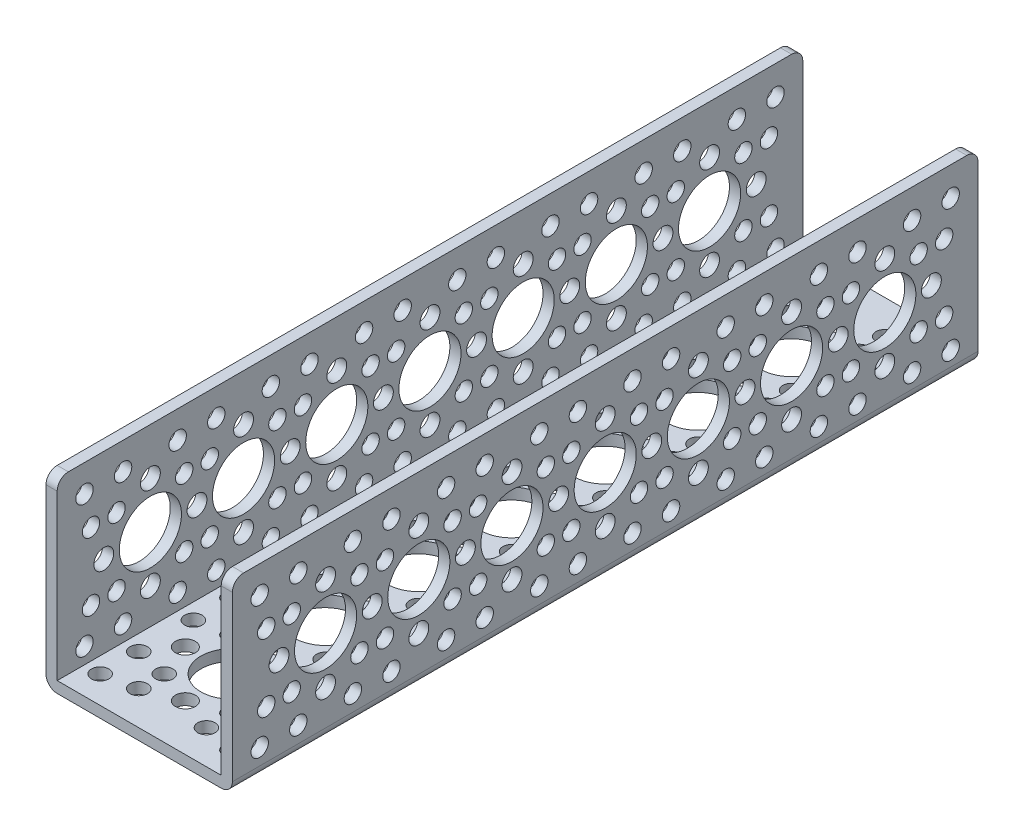
from build123d import *

# Parameters (mm, degrees)
EXTRUDE_THIN1_DEPTH = 152.4
SKETCH3_R           = 6.35
SKETCH3_R_2         = 2.032
SKETCH3_R_3         = 1.778
CUT_EXTRUDE1_DEPTH  = 2.286
SKETCH4_R           = 6.35
SKETCH4_R_2         = 2.032
SKETCH4_R_3         = 1.778
CUT_EXTRUDE2_DEPTH  = 39.1
FILLET1_R           = 2.286


with BuildPart() as part:
    # Sketch1 → Extrude-Thin1 (new body)
    with BuildSketch(Plane.XY):
        Polygon((0, 38.1), (0, 0), (38.1, 0), (38.1, 38.1), (35.814, 38.1), (35.814, 2.286), (2.286, 2.286), (2.286, 38.1), align=None)
    extrude(amount=EXTRUDE_THIN1_DEPTH)

    # Sketch3 → Cut-Extrude1 (cut)
    with BuildSketch(Plane.XZ):
        with Locations((19.05, 19.058384182)):
            Circle(SKETCH3_R)
        with Locations((19.05, 9.533384182)):
            Circle(SKETCH3_R_2)
        with Locations((9.525, 19.058384182)):
            Circle(SKETCH3_R_2)
        with Locations((19.05, 28.583384182)):
            Circle(SKETCH3_R_2)
        with Locations((28.575, 19.058384182)):
            Circle(SKETCH3_R_2)
        with Locations((12.135202787, 25.973181395)):
            Circle(SKETCH3_R_3)
        with Locations((5.579615818, 32.528768363)):
            Circle(SKETCH3_R_3)
        with Locations((25.964797213, 25.973181395)):
            Circle(SKETCH3_R_3)
        with Locations((32.520384182, 32.528768363)):
            Circle(SKETCH3_R_3)
        with Locations((25.964797213, 12.143586968)):
            Circle(SKETCH3_R_3)
        with Locations((32.520384182, 5.588)):
            Circle(SKETCH3_R_3)
        with Locations((12.135202787, 12.143586968)):
            Circle(SKETCH3_R_3)
        with Locations((5.579615818, 5.588)):
            Circle(SKETCH3_R_3)
        with Locations((12.135202787, 31.193586968)):
            Circle(SKETCH3_R_3)
        with Locations((25.964797213, 31.193586968)):
            Circle(SKETCH3_R_3)
        with Locations((25.964797213, 6.923181395)):
            Circle(SKETCH3_R_3)
        with Locations((12.135202787, 6.923181395)):
            Circle(SKETCH3_R_3)
        with Locations((32.520384182, 13.478768363)):
            Circle(SKETCH3_R_3)
        with Locations((5.579615818, 13.478768363)):
            Circle(SKETCH3_R_3)
        with Locations((5.579615818, 24.638)):
            Circle(SKETCH3_R_3)
        with Locations((32.520384182, 24.638)):
            Circle(SKETCH3_R_3)
        with Locations((18.971313238, 38.108384182)):
            Circle(SKETCH3_R)
        with Locations((9.446313238, 38.108384182)):
            Circle(SKETCH3_R_2)
        with Locations((28.496313238, 38.108384182)):
            Circle(SKETCH3_R_2)
        with Locations((18.971313238, 57.158384182)):
            Circle(SKETCH3_R)
        with Locations((18.971313238, 47.633384182)):
            Circle(SKETCH3_R_2)
        with Locations((9.446313238, 57.158384182)):
            Circle(SKETCH3_R_2)
        with Locations((18.971313238, 66.683384182)):
            Circle(SKETCH3_R_2)
        with Locations((28.496313238, 57.158384182)):
            Circle(SKETCH3_R_2)
        with Locations((12.056516025, 64.073181395)):
            Circle(SKETCH3_R_3)
        with Locations((5.500929056, 70.628768363)):
            Circle(SKETCH3_R_3)
        with Locations((25.886110451, 64.073181395)):
            Circle(SKETCH3_R_3)
        with Locations((32.441697419, 70.628768363)):
            Circle(SKETCH3_R_3)
        with Locations((25.886110451, 50.243586968)):
            Circle(SKETCH3_R_3)
        with Locations((32.441697419, 43.688)):
            Circle(SKETCH3_R_3)
        with Locations((12.056516025, 50.243586968)):
            Circle(SKETCH3_R_3)
        with Locations((5.500929056, 43.688)):
            Circle(SKETCH3_R_3)
        with Locations((12.056516025, 69.293586968)):
            Circle(SKETCH3_R_3)
        with Locations((25.886110451, 69.293586968)):
            Circle(SKETCH3_R_3)
        with Locations((25.886110451, 45.023181395)):
            Circle(SKETCH3_R_3)
        with Locations((12.056516025, 45.023181395)):
            Circle(SKETCH3_R_3)
        with Locations((32.441697419, 51.578768363)):
            Circle(SKETCH3_R_3)
        with Locations((5.500929056, 51.578768363)):
            Circle(SKETCH3_R_3)
        with Locations((5.500929056, 62.738)):
            Circle(SKETCH3_R_3)
        with Locations((32.441697419, 62.738)):
            Circle(SKETCH3_R_3)
        with Locations((18.971313238, 76.208384182)):
            Circle(SKETCH3_R)
        with Locations((9.446313238, 76.208384182)):
            Circle(SKETCH3_R_2)
        with Locations((28.496313238, 76.208384182)):
            Circle(SKETCH3_R_2)
        with Locations((18.971313238, 95.258384182)):
            Circle(SKETCH3_R)
        with Locations((18.971313238, 85.733384182)):
            Circle(SKETCH3_R_2)
        with Locations((9.446313238, 95.258384182)):
            Circle(SKETCH3_R_2)
        with Locations((18.971313238, 104.783384182)):
            Circle(SKETCH3_R_2)
        with Locations((28.496313238, 95.258384182)):
            Circle(SKETCH3_R_2)
        with Locations((12.056516025, 102.173181395)):
            Circle(SKETCH3_R_3)
        with Locations((5.500929056, 108.728768363)):
            Circle(SKETCH3_R_3)
        with Locations((25.886110451, 102.173181395)):
            Circle(SKETCH3_R_3)
        with Locations((32.441697419, 108.728768363)):
            Circle(SKETCH3_R_3)
        with Locations((25.886110451, 88.343586968)):
            Circle(SKETCH3_R_3)
        with Locations((32.441697419, 81.788)):
            Circle(SKETCH3_R_3)
        with Locations((12.056516025, 88.343586968)):
            Circle(SKETCH3_R_3)
        with Locations((5.500929056, 81.788)):
            Circle(SKETCH3_R_3)
        with Locations((12.056516025, 107.393586968)):
            Circle(SKETCH3_R_3)
        with Locations((25.886110451, 107.393586968)):
            Circle(SKETCH3_R_3)
        with Locations((25.886110451, 83.123181395)):
            Circle(SKETCH3_R_3)
        with Locations((12.056516025, 83.123181395)):
            Circle(SKETCH3_R_3)
        with Locations((32.441697419, 89.678768363)):
            Circle(SKETCH3_R_3)
        with Locations((5.500929056, 89.678768363)):
            Circle(SKETCH3_R_3)
        with Locations((5.500929056, 100.838)):
            Circle(SKETCH3_R_3)
        with Locations((32.441697419, 100.838)):
            Circle(SKETCH3_R_3)
        with Locations((18.971313238, 133.358384182)):
            Circle(SKETCH3_R)
        with Locations((18.971313238, 123.833384182)):
            Circle(SKETCH3_R_2)
        with Locations((9.446313238, 133.358384182)):
            Circle(SKETCH3_R_2)
        with Locations((18.971313238, 142.883384182)):
            Circle(SKETCH3_R_2)
        with Locations((28.496313238, 133.358384182)):
            Circle(SKETCH3_R_2)
        with Locations((12.056516025, 140.273181395)):
            Circle(SKETCH3_R_3)
        with Locations((5.500929056, 146.828768363)):
            Circle(SKETCH3_R_3)
        with Locations((25.886110451, 140.273181395)):
            Circle(SKETCH3_R_3)
        with Locations((32.441697419, 146.828768363)):
            Circle(SKETCH3_R_3)
        with Locations((25.886110451, 126.443586968)):
            Circle(SKETCH3_R_3)
        with Locations((32.441697419, 119.888)):
            Circle(SKETCH3_R_3)
        with Locations((12.056516025, 126.443586968)):
            Circle(SKETCH3_R_3)
        with Locations((5.500929056, 119.888)):
            Circle(SKETCH3_R_3)
        with Locations((12.056516025, 145.493586968)):
            Circle(SKETCH3_R_3)
        with Locations((25.886110451, 145.493586968)):
            Circle(SKETCH3_R_3)
        with Locations((25.886110451, 121.223181395)):
            Circle(SKETCH3_R_3)
        with Locations((12.056516025, 121.223181395)):
            Circle(SKETCH3_R_3)
        with Locations((32.441697419, 127.778768363)):
            Circle(SKETCH3_R_3)
        with Locations((5.500929056, 127.778768363)):
            Circle(SKETCH3_R_3)
        with Locations((5.500929056, 138.938)):
            Circle(SKETCH3_R_3)
        with Locations((32.441697419, 138.938)):
            Circle(SKETCH3_R_3)
        with Locations((18.971313238, 114.308384182)):
            Circle(SKETCH3_R)
        with Locations((9.446313238, 114.308384182)):
            Circle(SKETCH3_R_2)
        with Locations((28.496313238, 114.308384182)):
            Circle(SKETCH3_R_2)
    extrude(amount=-CUT_EXTRUDE1_DEPTH, mode=Mode.SUBTRACT)

    # Sketch4 → Cut-Extrude2 (cut, through all)
    with BuildSketch(Plane.ZY):
        with Locations((114.3, 19.05)):
            Circle(SKETCH4_R)
        with Locations((114.3, 9.525)):
            Circle(SKETCH4_R_2)
        with Locations((114.3, 28.575)):
            Circle(SKETCH4_R_2)
        with Locations((95.25, 19.05)):
            Circle(SKETCH4_R)
        with Locations((104.774999983, 19.049430852)):
            Circle(SKETCH4_R_2)
        with Locations((95.249430852, 9.525000017)):
            Circle(SKETCH4_R_2)
        with Locations((85.725000017, 19.050569148)):
            Circle(SKETCH4_R_2)
        with Locations((95.250569148, 28.574999983)):
            Circle(SKETCH4_R_2)
        with Locations((88.334789619, 12.13561598)):
            Circle(SKETCH4_R_3)
        with Locations((81.778810945, 5.58042074)):
            Circle(SKETCH4_R_3)
        with Locations((88.33561598, 25.965210381)):
            Circle(SKETCH4_R_3)
        with Locations((81.78042074, 32.521189055)):
            Circle(SKETCH4_R_3)
        with Locations((102.165210381, 25.96438402)):
            Circle(SKETCH4_R_3)
        with Locations((108.721189055, 32.51957926)):
            Circle(SKETCH4_R_3)
        with Locations((102.16438402, 12.134789619)):
            Circle(SKETCH4_R_3)
        with Locations((108.71957926, 5.578810945)):
            Circle(SKETCH4_R_3)
        with Locations((83.114384054, 12.135927915)):
            Circle(SKETCH4_R_3)
        with Locations((83.115210415, 25.965522317)):
            Circle(SKETCH4_R_3)
        with Locations((107.385615946, 25.964072085)):
            Circle(SKETCH4_R_3)
        with Locations((107.384789585, 12.134477683)):
            Circle(SKETCH4_R_3)
        with Locations((100.830420706, 32.520050758)):
            Circle(SKETCH4_R_3)
        with Locations((100.828810911, 5.579282443)):
            Circle(SKETCH4_R_3)
        with Locations((89.669579294, 5.579949242)):
            Circle(SKETCH4_R_3)
        with Locations((89.671189089, 32.520717557)):
            Circle(SKETCH4_R_3)
        with Locations((133.35, 19.05)):
            Circle(SKETCH4_R)
        with Locations((142.875, 19.05)):
            Circle(SKETCH4_R_2)
        with Locations((133.35, 9.525)):
            Circle(SKETCH4_R_2)
        with Locations((123.825, 19.05)):
            Circle(SKETCH4_R_2)
        with Locations((133.35, 28.575)):
            Circle(SKETCH4_R_2)
        with Locations((126.435202787, 12.135202787)):
            Circle(SKETCH4_R_3)
        with Locations((119.879615818, 5.579615818)):
            Circle(SKETCH4_R_3)
        with Locations((126.435202787, 25.964797213)):
            Circle(SKETCH4_R_3)
        with Locations((119.879615818, 32.520384182)):
            Circle(SKETCH4_R_3)
        with Locations((140.264797213, 25.964797213)):
            Circle(SKETCH4_R_3)
        with Locations((146.820384182, 32.520384182)):
            Circle(SKETCH4_R_3)
        with Locations((140.264797213, 12.135202787)):
            Circle(SKETCH4_R_3)
        with Locations((146.820384182, 5.579615818)):
            Circle(SKETCH4_R_3)
        with Locations((121.214797213, 12.135202787)):
            Circle(SKETCH4_R_3)
        with Locations((121.214797213, 25.964797213)):
            Circle(SKETCH4_R_3)
        with Locations((145.485202787, 25.964797213)):
            Circle(SKETCH4_R_3)
        with Locations((145.485202787, 12.135202787)):
            Circle(SKETCH4_R_3)
        with Locations((138.929615818, 32.520384182)):
            Circle(SKETCH4_R_3)
        with Locations((138.929615818, 5.579615818)):
            Circle(SKETCH4_R_3)
        with Locations((127.770384182, 5.579615818)):
            Circle(SKETCH4_R_3)
        with Locations((127.770384182, 32.520384182)):
            Circle(SKETCH4_R_3)
        with Locations((76.200189489, 18.96503245)):
            Circle(SKETCH4_R)
        with Locations((76.200189489, 9.44003245)):
            Circle(SKETCH4_R_2)
        with Locations((76.200189489, 28.49003245)):
            Circle(SKETCH4_R_2)
        with Locations((57.150378977, 18.880064901)):
            Circle(SKETCH4_R)
        with Locations((66.67537896, 18.879495752)):
            Circle(SKETCH4_R_2)
        with Locations((57.149809829, 9.355064918)):
            Circle(SKETCH4_R_2)
        with Locations((47.625378994, 18.880634049)):
            Circle(SKETCH4_R_2)
        with Locations((57.150948126, 28.405064884)):
            Circle(SKETCH4_R_2)
        with Locations((50.235168596, 11.96568088)):
            Circle(SKETCH4_R_3)
        with Locations((43.679189923, 5.41048564)):
            Circle(SKETCH4_R_3)
        with Locations((50.235994957, 25.795275282)):
            Circle(SKETCH4_R_3)
        with Locations((43.680799717, 32.351253955)):
            Circle(SKETCH4_R_3)
        with Locations((64.065589359, 25.794448921)):
            Circle(SKETCH4_R_3)
        with Locations((70.621568032, 32.349644161)):
            Circle(SKETCH4_R_3)
        with Locations((64.064762998, 11.964854519)):
            Circle(SKETCH4_R_3)
        with Locations((70.619958238, 5.408875846)):
            Circle(SKETCH4_R_3)
        with Locations((45.014763032, 11.965992816)):
            Circle(SKETCH4_R_3)
        with Locations((45.015589393, 25.795587217)):
            Circle(SKETCH4_R_3)
        with Locations((69.285994923, 25.794136985)):
            Circle(SKETCH4_R_3)
        with Locations((69.285168562, 11.964542584)):
            Circle(SKETCH4_R_3)
        with Locations((62.730799683, 32.350115659)):
            Circle(SKETCH4_R_3)
        with Locations((62.729189889, 5.409347344)):
            Circle(SKETCH4_R_3)
        with Locations((51.569958272, 5.410014142)):
            Circle(SKETCH4_R_3)
        with Locations((51.571568066, 32.350782457)):
            Circle(SKETCH4_R_3)
        with Locations((38.100568466, 18.795097351)):
            Circle(SKETCH4_R)
        with Locations((38.100568466, 9.270097351)):
            Circle(SKETCH4_R_2)
        with Locations((38.100568466, 28.320097351)):
            Circle(SKETCH4_R_2)
        with Locations((19.050757955, 18.710129801)):
            Circle(SKETCH4_R)
        with Locations((28.575757938, 18.709560653)):
            Circle(SKETCH4_R_2)
        with Locations((19.050188807, 9.185129818)):
            Circle(SKETCH4_R_2)
        with Locations((9.525757972, 18.710698949)):
            Circle(SKETCH4_R_2)
        with Locations((19.051327103, 28.235129784)):
            Circle(SKETCH4_R_2)
        with Locations((12.135547573, 11.795745781)):
            Circle(SKETCH4_R_3)
        with Locations((5.5795689, 5.240550541)):
            Circle(SKETCH4_R_3)
        with Locations((12.136373935, 25.625340183)):
            Circle(SKETCH4_R_3)
        with Locations((5.581178695, 32.181318856)):
            Circle(SKETCH4_R_3)
        with Locations((25.965968336, 25.624513821)):
            Circle(SKETCH4_R_3)
        with Locations((32.52194701, 32.179709061)):
            Circle(SKETCH4_R_3)
        with Locations((25.965141975, 11.79491942)):
            Circle(SKETCH4_R_3)
        with Locations((32.520337215, 5.238940746)):
            Circle(SKETCH4_R_3)
        with Locations((6.915142009, 11.796057716)):
            Circle(SKETCH4_R_3)
        with Locations((6.91596837, 25.625652118)):
            Circle(SKETCH4_R_3)
        with Locations((31.186373901, 25.624201886)):
            Circle(SKETCH4_R_3)
        with Locations((31.185547539, 11.794607484)):
            Circle(SKETCH4_R_3)
        with Locations((24.631178661, 32.180180559)):
            Circle(SKETCH4_R_3)
        with Locations((24.629568866, 5.239412244)):
            Circle(SKETCH4_R_3)
        with Locations((13.470337249, 5.240079043)):
            Circle(SKETCH4_R_3)
        with Locations((13.471947044, 32.180847358)):
            Circle(SKETCH4_R_3)
    extrude(amount=-CUT_EXTRUDE2_DEPTH, mode=Mode.SUBTRACT)

    # Fillet1
    fillet1_edges = [part.edges().sort_by_distance(p)[0] for p in [
        (38.1, 0, 76.2),
        (0, 0, 76.2),
        (36.957, 38.1, 152.4),
        (1.143, 38.1, 152.4),
        (36.957, 38.1, 0),
        (1.143, 38.1, 0),
    ]]
    fillet(fillet1_edges, radius=FILLET1_R)


solid = part.part
